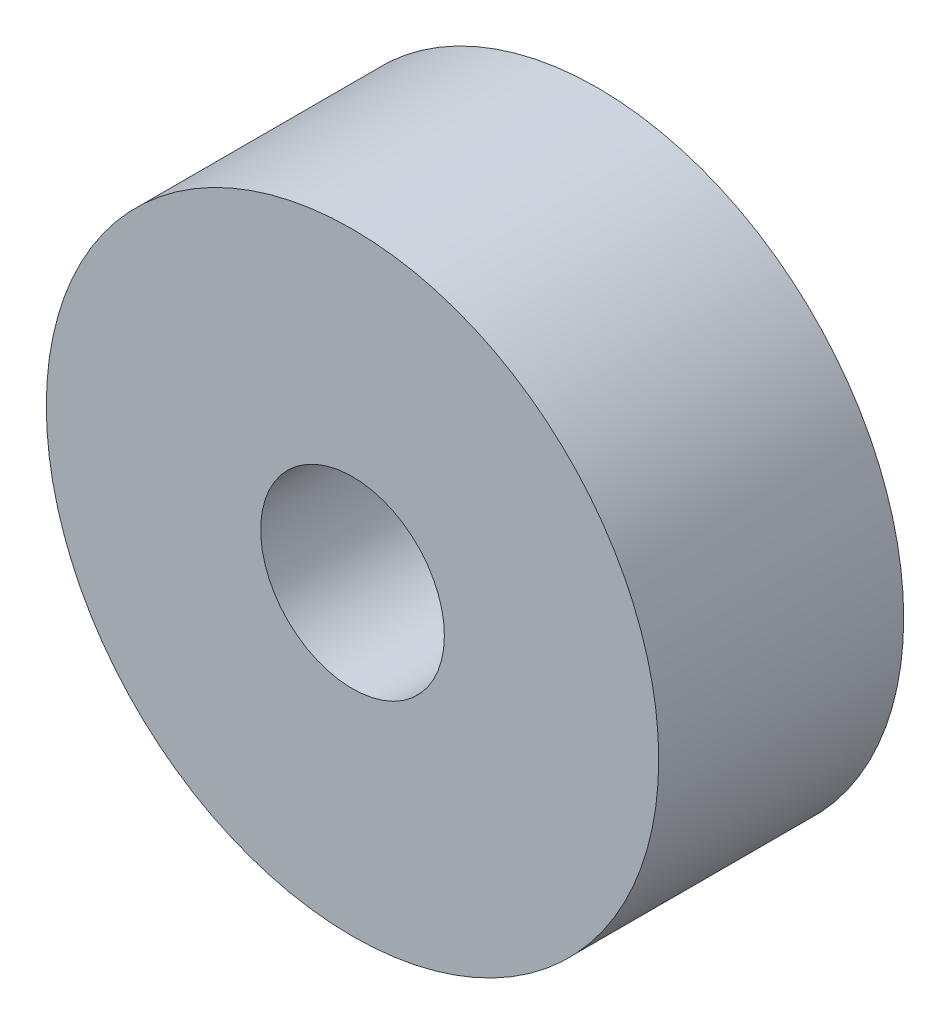
from build123d import *

# Parameters (mm, degrees)
SKETCH_1_R      = 5
SKETCH_1_R_2    = 1.5
EXTRUDE_1_DEPTH = 4


with BuildPart() as part:
    # Эскиз1 → Бобышка-Вытянуть1 (new body)
    with BuildSketch(Plane.XY):
        Circle(SKETCH_1_R)
        Circle(SKETCH_1_R_2, mode=Mode.SUBTRACT)
    extrude(amount=EXTRUDE_1_DEPTH)


solid = part.part
